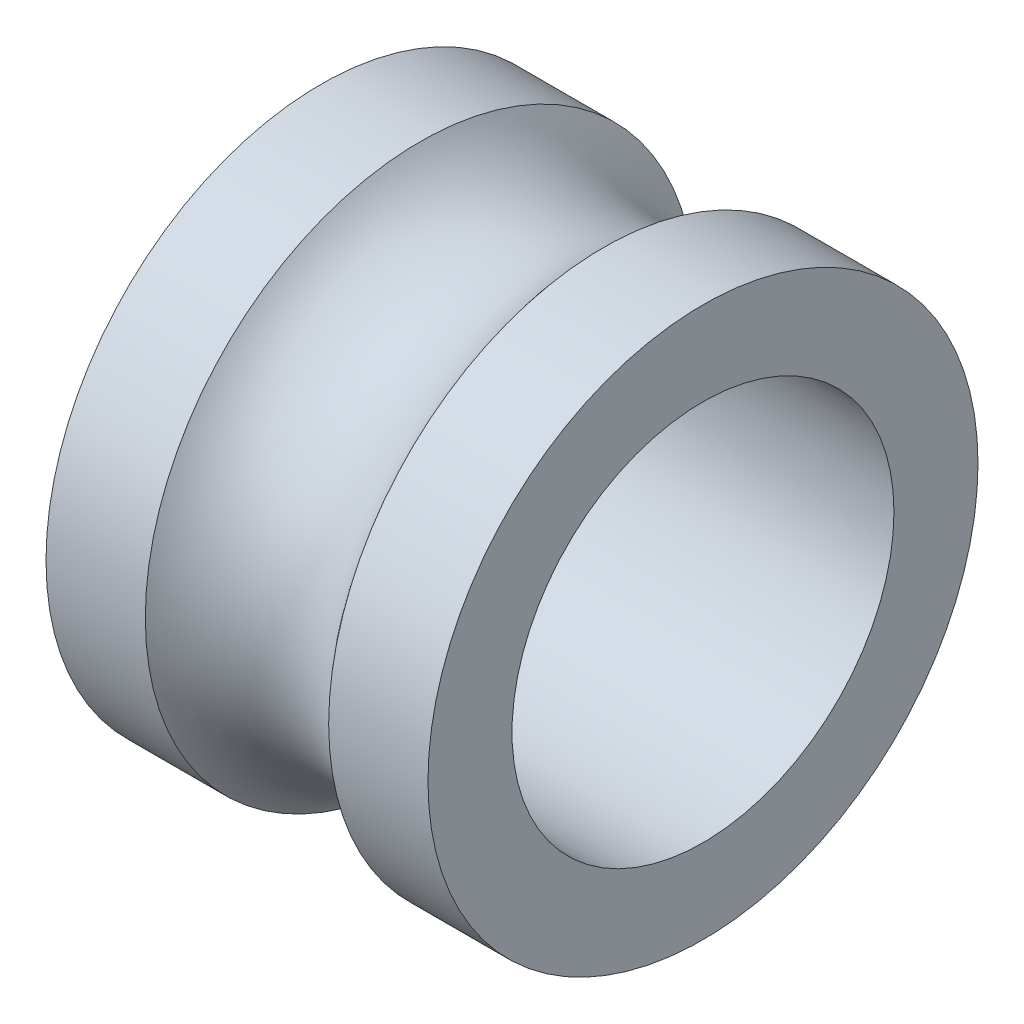
from build123d import *


with BuildPart() as part:
    # Çizim1 → Döndür1 (revolve)
    with BuildSketch(Plane.XY):
        with BuildLine():
            Line((2.5, 2.5), (-2.5, 2.5))
            Line((-2.5, 2.5), (-2.5, 3.6))
            Line((-2.5, 3.6), (-1.2, 3.6))
            ThreePointArc((-1.2, 3.6), (0, 3), (1.2, 3.6))
            Line((1.2, 3.6), (2.5, 3.6))
            Line((2.5, 3.6), (2.5, 2.5))
        make_face()
    revolve(axis=Axis((0, 0, 0), (-1, 0, 0)))


solid = part.part
